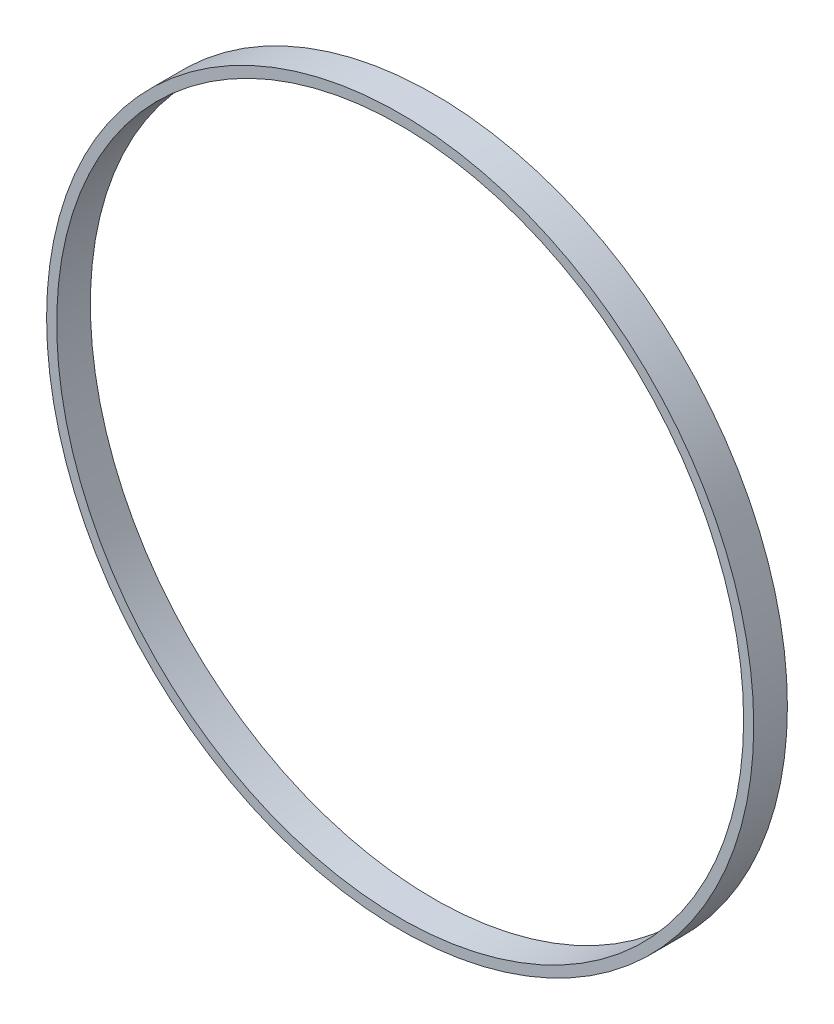
from build123d import *

# Parameters (mm, degrees)
SKETCH1_R           = 52.5
SKETCH1_R_2         = 51
BOSS_EXTRUDE1_DEPTH = 5


with BuildPart() as part:
    # Sketch1 → Boss-Extrude1 (new body)
    with BuildSketch(Plane.XY):
        Circle(SKETCH1_R)
        Circle(SKETCH1_R_2, mode=Mode.SUBTRACT)
    extrude(amount=BOSS_EXTRUDE1_DEPTH)


solid = part.part
